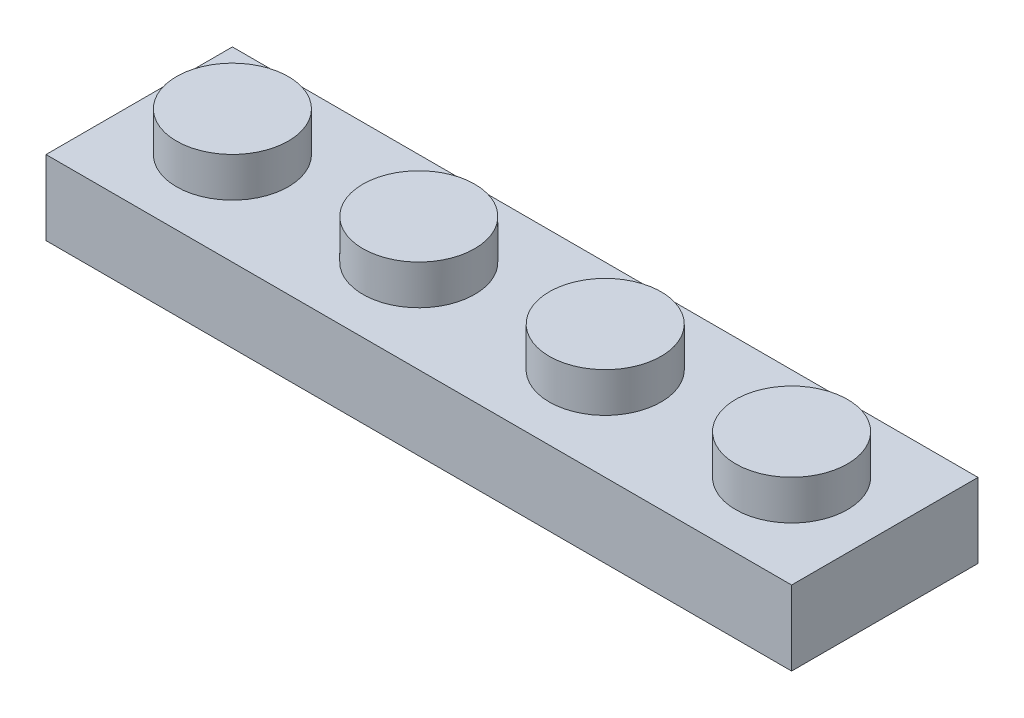
from build123d import *

# Parameters (mm, degrees)
SKETCH_1_W             = 8
SKETCH_1_H             = 8
HEIGHT_DEPTH           = 3.2
SKETCH_2_R             = 2.4
EXTRUDE_2_DEPTH        = 1.7
PATTERN_LINEAR_1_COUNT = 4
PATTERN_LINEAR_1_PITCH = 8
SHELL_1_T              = -1.6


with BuildPart() as part:
    # 草圖1 → height (new body)
    with BuildSketch(Plane(origin=(0, 0, 0), x_dir=(1, 0, 0), z_dir=(0, 1, 0))):
        Rectangle(SKETCH_1_W, SKETCH_1_H)
    height = extrude(amount=HEIGHT_DEPTH)

    # 草圖2 → 填料-伸長2 (add)
    with BuildSketch(Plane(origin=(0, 3.2, 0), x_dir=(1, 0, 0), z_dir=(0, 1, 0))):
        Circle(SKETCH_2_R)
    extrude_2 = extrude(amount=EXTRUDE_2_DEPTH)

    # 直線複製排列1: height, 填料-伸長2 ×4
    with Locations(*[(i * PATTERN_LINEAR_1_PITCH, 0, 0) for i in range(1, PATTERN_LINEAR_1_COUNT)]):
        add(height)
        add(extrude_2)

    # 薄殼1
    shell_1_openings = [part.faces().sort_by_distance(p)[0] for p in [
        (12, 0, 0),
    ]]
    offset(amount=SHELL_1_T, openings=shell_1_openings, kind=Kind.INTERSECTION)


solid = part.part
